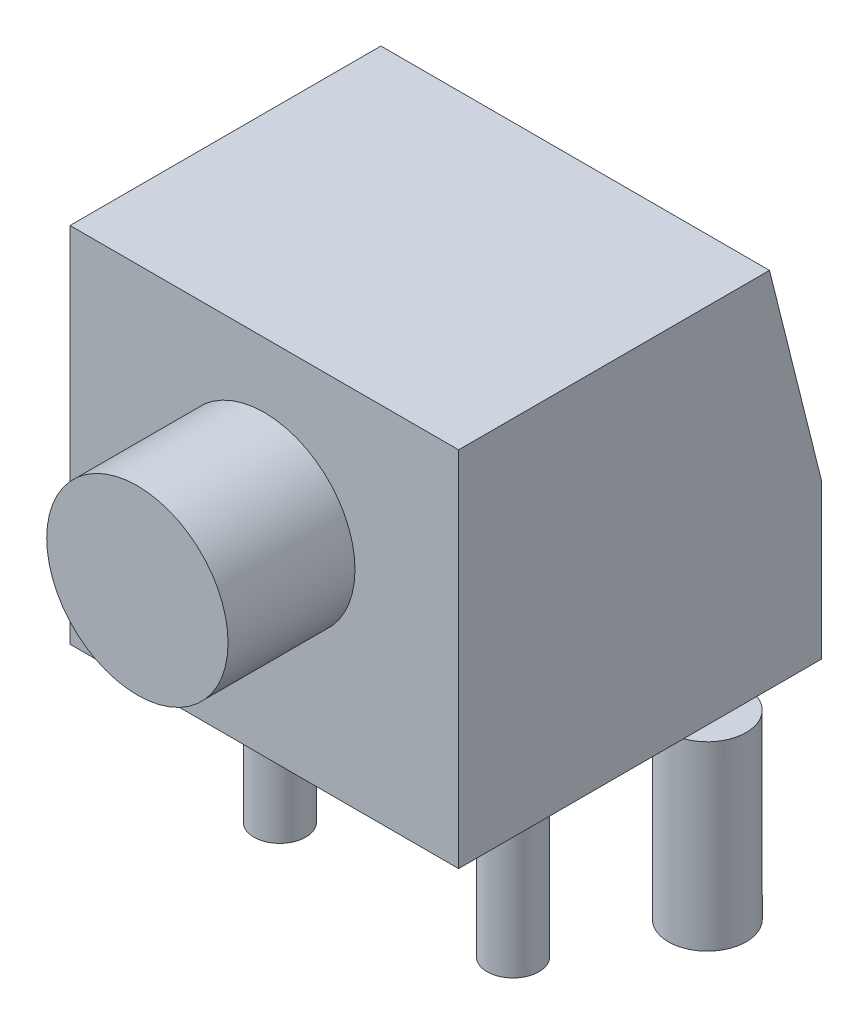
from build123d import *

# Parameters (mm, degrees)
EXTRUDE_1_DEPTH = 3.75
SKETCH_4_R      = 0.75
SKETCH_4_R_2    = 0.5
EXTRUDE_3_DEPTH = 3.5
SKETCH_3_R      = 1.75
EXTRUDE_2_DEPTH = 2.45


with BuildPart() as part:
    # 草图2 → 凸台-拉伸1 (new body, symmetric)
    with BuildSketch(Plane(origin=(0, 0, 0), x_dir=(0, 0, -1), z_dir=(1, 0, 0))):
        Polygon((-2.55, 0), (4.45, 0), (4.45, 3), (3.45, 7), (-2.55, 7), align=None)
    extrude(amount=EXTRUDE_1_DEPTH, both=True)

    # 草图4 → 凸台-拉伸3 (add)
    with BuildSketch(Plane.XZ):
        with Locations((-3.5, -2.5)):
            Circle(SKETCH_4_R)
        with Locations((-2.25, 0)):
            Circle(SKETCH_4_R_2)
        with Locations((2.25, 0)):
            Circle(SKETCH_4_R_2)
        with Locations((3.5, -2.5)):
            Circle(SKETCH_4_R)
    extrude(amount=EXTRUDE_3_DEPTH)

    # 草图3 → 凸台-拉伸2 (add)
    with BuildSketch(Plane.XY.offset(2.55)):
        with Locations((0, 4)):
            Circle(SKETCH_3_R)
    extrude(amount=EXTRUDE_2_DEPTH)


solid = part.part
